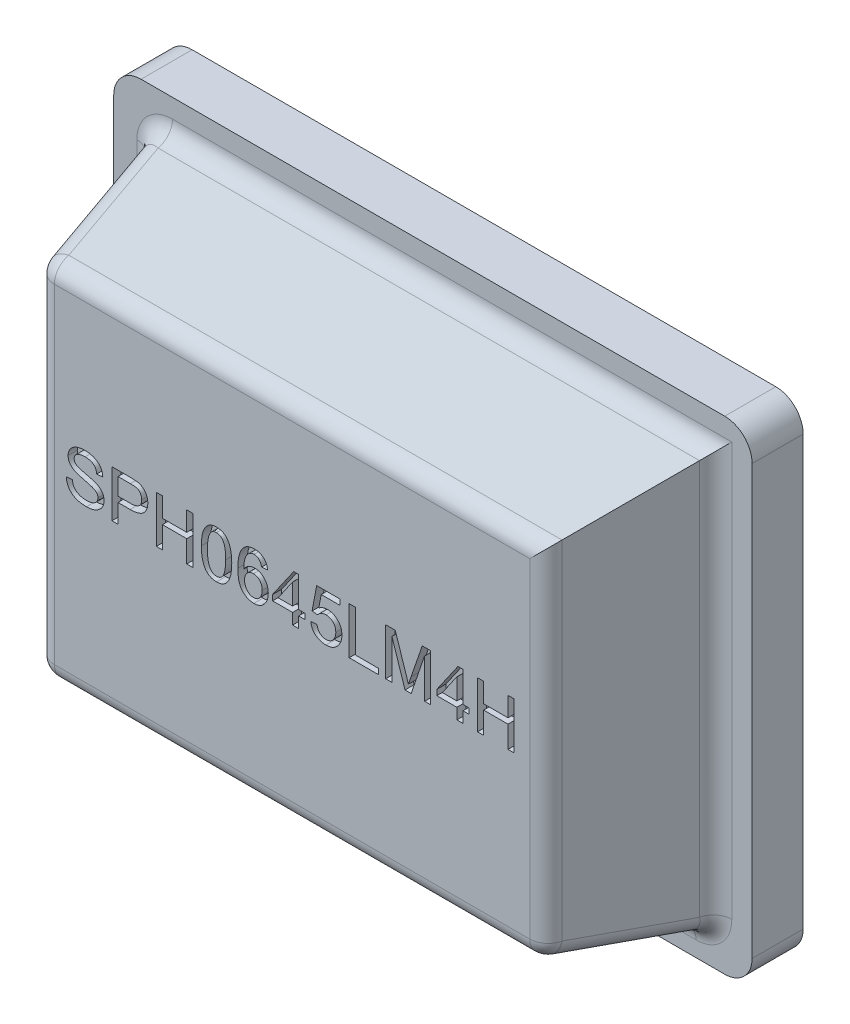
from build123d import *

# Parameters (mm, degrees)
BOSS_EXTRU_1_DEPTH      = 0.28
ESQUISSE2_W             = 3.1
ESQUISSE2_H             = 2.3
BOSS_EXTRU_2_DEPTH      = 0.78
BOSS_EXTRU_2_TAPER      = 12
CONG_1_R                = 0.1
ENL_V_MAT_EXTRU_1_DEPTH = 0.05


with BuildPart() as part:
    # Esquisse1 → Boss.-Extru.1 (new body)
    with BuildSketch(Plane.XY):
        with BuildLine():
            Line((0.15, 0), (3.35, 0))
            ThreePointArc((3.35, 0), (3.456066017, 0.043933983), (3.5, 0.15))
            Line((3.5, 0.15), (3.5, 2.5))
            ThreePointArc((3.5, 2.5), (3.456066017, 2.606066017), (3.35, 2.65))
            Line((3.35, 2.65), (0.15, 2.65))
            ThreePointArc((0.15, 2.65), (0.043933983, 2.606066017), (0, 2.5))
            Line((0, 2.5), (0, 0.15))
            ThreePointArc((0, 0.15), (0.043933983, 0.043933983), (0.15, 0))
        make_face()
    extrude(amount=BOSS_EXTRU_1_DEPTH)

    # Esquisse2 → Boss.-Extru.2 (add)
    with BuildSketch(Plane.XY.offset(0.28)):
        with Locations((1.757802222, 1.315831267)):
            Rectangle(ESQUISSE2_W, ESQUISSE2_H)
    extrude(amount=BOSS_EXTRU_2_DEPTH, taper=BOSS_EXTRU_2_TAPER)

    # Congé1
    cong_1_edges = [part.edges().sort_by_distance(p)[0] for p in [
        (3.307802222, 1.315831267, 0.28),
        (3.224905163, 0.248728326, 0.67),
        (1.757802222, 2.465831267, 0.28),
        (0.207802222, 1.315831267, 0.28),
        (0.290699281, 2.382934208, 0.67),
        (1.757802222, 0.165831267, 0.28),
        (0.290699281, 0.248728326, 0.67),
        (3.142008104, 1.315831267, 1.06),
        (1.757802222, 2.300037149, 1.06),
        (0.37359634, 1.315831267, 1.06),
        (1.757802222, 0.331625385, 1.06),
    ]]
    fillet(cong_1_edges, radius=CONG_1_R)

    # Esquisse3 → Enlèv. mat.-Extru.1 (cut)
    with BuildSketch(Plane.XY.offset(1.06)):
        with BuildLine():
            add(Edge.make_bspline(
                [(0.686708644, 1.433601943), (0.686504725, 1.43562293), (0.686108091, 1.43955386), (0.684873786, 1.445215749), (0.683268561, 1.450504259), (0.681247803, 1.45542207), (0.678770932, 1.459938726), (0.675913819, 1.464100808), (0.672530404, 1.467807634), (0.668775366, 1.471170066), (0.664558544, 1.474094485), (0.659946497, 1.476651772), (0.654913128, 1.478860313), (0.64942557, 1.480616442), (0.643509104, 1.481949886), (0.637191239, 1.482946813), (0.630432628, 1.48350904), (0.62578506, 1.483591547), (0.623386663, 1.483634125)],
                knots=[0, 0, 0, 0, 6.089e-06, 1.1844e-05, 1.735e-05, 2.2654e-05, 2.7762e-05, 3.2779e-05, 3.7761e-05, 4.2781e-05, 4.787e-05, 5.312e-05, 5.8581e-05, 6.4333e-05, 7.0376e-05, 7.6759e-05, 8.3507e-05, 9.0702e-05, 9.0702e-05, 9.0702e-05, 9.0702e-05], degree=3))
            add(Edge.make_bspline(
                [(0.623386663, 1.483634125), (0.62121399, 1.483607457), (0.616967623, 1.483555337), (0.610761815, 1.483051413), (0.604850987, 1.482373919), (0.599274567, 1.481246443), (0.593975058, 1.479906152), (0.588983976, 1.478256413), (0.584312977, 1.476265694), (0.58000664, 1.473983255), (0.576066465, 1.471462847), (0.572662831, 1.468577026), (0.569760216, 1.465433997), (0.567389574, 1.462014967), (0.565532077, 1.458316689), (0.564242188, 1.454327079), (0.563432427, 1.450051385), (0.563342272, 1.447103966), (0.563295928, 1.44558882)],
                knots=[0, 0, 0, 0, 6.516e-06, 1.2736e-05, 1.867e-05, 2.4353e-05, 2.9789e-05, 3.5062e-05, 4.0106e-05, 4.5002e-05, 4.9671e-05, 5.4109e-05, 5.8351e-05, 6.2471e-05, 6.655e-05, 7.0719e-05, 7.5012e-05, 7.9554e-05, 7.9554e-05, 7.9554e-05, 7.9554e-05], degree=3))
            add(Edge.make_bspline(
                [(0.563295928, 1.44558882), (0.563340109, 1.444266954), (0.563426572, 1.441680013), (0.563977787, 1.43792657), (0.565004176, 1.434441006), (0.566323037, 1.431188028), (0.568136658, 1.428245141), (0.570305555, 1.425547274), (0.572851353, 1.423095932), (0.575888084, 1.420910558), (0.57947096, 1.418844765), (0.583744959, 1.416862243), (0.588718663, 1.414795005), (0.59449778, 1.412878645), (0.600954167, 1.410766058), (0.608196515, 1.408754951), (0.616155253, 1.406723822), (0.621733286, 1.405446404), (0.624637468, 1.404781322)],
                knots=[0, 0, 0, 0, 3.966e-06, 7.762e-06, 1.1342e-05, 1.4846e-05, 1.826e-05, 2.167e-05, 2.5209e-05, 2.8826e-05, 3.2866e-05, 3.7599e-05, 4.2951e-05, 4.9016e-05, 5.5856e-05, 6.333e-05, 7.1559e-05, 8.0496e-05, 8.0496e-05, 8.0496e-05, 8.0496e-05], degree=3))
            add(Edge.make_bspline(
                [(0.624637468, 1.404781322), (0.629769119, 1.403628786), (0.639575354, 1.401426368), (0.653475203, 1.397830233), (0.665910853, 1.394243676), (0.67705924, 1.390630254), (0.687146055, 1.386470947), (0.696291146, 1.381234319), (0.704735456, 1.37506955), (0.7111137, 1.369096867), (0.715649875, 1.36376883), (0.718653309, 1.359422065), (0.721136843, 1.354722135), (0.723199876, 1.349696507), (0.724796536, 1.344353518), (0.725946641, 1.338668336), (0.726631977, 1.332668611), (0.726699743, 1.328553557), (0.726734389, 1.326449686)],
                knots=[0, 0, 0, 0, 1.5778e-05, 3.015e-05, 4.3065e-05, 5.4601e-05, 6.5297e-05, 7.5731e-05, 8.6134e-05, 9.6604e-05, 0.000101856, 0.000107103, 0.000112419, 0.000117771, 0.000123377, 0.000129121, 0.000135153, 0.000141462, 0.000141462, 0.000141462, 0.000141462], degree=3))
            add(Edge.make_bspline(
                [(0.726734389, 1.326449686), (0.72665664, 1.323769377), (0.726503298, 1.318483051), (0.725217205, 1.310735349), (0.72313559, 1.303334025), (0.720196405, 1.29629749), (0.71639635, 1.289629279), (0.711790457, 1.283293516), (0.706307393, 1.277331831), (0.700086792, 1.271736517), (0.693205066, 1.266651967), (0.685728734, 1.262258584), (0.677782956, 1.258490024), (0.66932344, 1.255406898), (0.660343525, 1.253091494), (0.650891838, 1.251347698), (0.640900726, 1.250378547), (0.634072587, 1.250227762), (0.630578789, 1.250150609)],
                knots=[0, 0, 0, 0, 8.037e-06, 1.5851e-05, 2.3489e-05, 3.1058e-05, 3.8667e-05, 4.6464e-05, 5.4507e-05, 6.2921e-05, 7.1531e-05, 8.0129e-05, 8.8895e-05, 9.788e-05, 0.000107095, 0.000116684, 0.000126688, 0.000137169, 0.000137169, 0.000137169, 0.000137169], degree=3))
            add(Edge.make_bspline(
                [(0.630578789, 1.250150609), (0.62616366, 1.250212664), (0.617595461, 1.250333091), (0.605175967, 1.251486804), (0.593624562, 1.253395141), (0.582934087, 1.256044889), (0.573075061, 1.25941463), (0.564057257, 1.263572777), (0.555918877, 1.268558097), (0.548640564, 1.274258888), (0.54224423, 1.280583066), (0.536615818, 1.287351617), (0.531776207, 1.294566629), (0.527837127, 1.302290693), (0.524546581, 1.310398153), (0.522186479, 1.31900771), (0.520518245, 1.328041244), (0.520131334, 1.334242641), (0.519934703, 1.337394226)],
                knots=[0, 0, 0, 0, 1.3243e-05, 2.5699e-05, 3.7378e-05, 4.8337e-05, 5.8704e-05, 6.859e-05, 7.8065e-05, 8.7271e-05, 9.6263e-05, 0.000104998, 0.000113641, 0.000122266, 0.000130966, 0.000139843, 0.000149003, 0.000158469, 0.000158469, 0.000158469, 0.000158469], degree=3))
            Line((0.519934703, 1.337394226), (0.553289491, 1.340208536))
            add(Edge.make_bspline(
                [(0.553289491, 1.340208536), (0.553540517, 1.337683447), (0.554030292, 1.332756774), (0.555484797, 1.325662004), (0.557550258, 1.319094159), (0.560309636, 1.313101746), (0.563564585, 1.307579746), (0.56753152, 1.302655137), (0.57204413, 1.298220434), (0.577166402, 1.294400475), (0.582717291, 1.291081432), (0.588561247, 1.288172941), (0.594669199, 1.285626083), (0.601109268, 1.283686002), (0.607793057, 1.282115051), (0.61473775, 1.280967327), (0.621965166, 1.280272554), (0.62687692, 1.280204566), (0.629380102, 1.280169918)],
                knots=[0, 0, 0, 0, 7.609e-06, 1.4845e-05, 2.1685e-05, 2.8216e-05, 3.4597e-05, 4.0864e-05, 4.713e-05, 5.353e-05, 5.9983e-05, 6.6509e-05, 7.31e-05, 7.9809e-05, 8.6661e-05, 9.3687e-05, 0.000100911, 0.000108418, 0.000108418, 0.000108418, 0.000108418], degree=3))
            add(Edge.make_bspline(
                [(0.629380102, 1.280169918), (0.631709619, 1.28018809), (0.636271989, 1.280223679), (0.6429305, 1.280848267), (0.649263821, 1.28167395), (0.655221456, 1.283021405), (0.660863148, 1.284599591), (0.666158462, 1.286598437), (0.671119623, 1.288932486), (0.675697923, 1.291627459), (0.679824903, 1.294642713), (0.683444451, 1.297942315), (0.686562464, 1.301472909), (0.689028443, 1.305342301), (0.69096283, 1.309425309), (0.692401614, 1.313757725), (0.693247452, 1.318373116), (0.693334962, 1.321547195), (0.693379601, 1.323166324)],
                knots=[0, 0, 0, 0, 6.985e-06, 1.3681e-05, 2.0049e-05, 2.6132e-05, 3.1987e-05, 3.7611e-05, 4.309e-05, 4.8417e-05, 5.3525e-05, 5.8394e-05, 6.3086e-05, 6.7611e-05, 7.211e-05, 7.661e-05, 8.1271e-05, 8.6125e-05, 8.6125e-05, 8.6125e-05, 8.6125e-05], degree=3))
            add(Edge.make_bspline(
                [(0.693379601, 1.323166324), (0.693311881, 1.324836734), (0.693179804, 1.328094608), (0.692377587, 1.332812703), (0.690873449, 1.337151472), (0.68885353, 1.34117316), (0.686124915, 1.344769338), (0.682948779, 1.348120846), (0.679061862, 1.350973659), (0.674600802, 1.353542019), (0.669477383, 1.355940824), (0.663606078, 1.35825266), (0.656992374, 1.36065761), (0.649583372, 1.363043331), (0.641386398, 1.365414482), (0.632421332, 1.367899345), (0.622634717, 1.370246892), (0.612327813, 1.372616252), (0.602003992, 1.375056027), (0.592200947, 1.377794332), (0.583165542, 1.380829343), (0.574874106, 1.384035796), (0.567344428, 1.387462259), (0.56058994, 1.391121965), (0.554550928, 1.394947895), (0.549294609, 1.399105248), (0.544700895, 1.403506366), (0.540770542, 1.4082391), (0.537398468, 1.413252345), (0.53468781, 1.418619642), (0.532515319, 1.424286447), (0.53102852, 1.430290688), (0.530123855, 1.436597187), (0.530002851, 1.440895229), (0.529941139, 1.443087211)],
                knots=[0, 0, 0, 0, 5.013e-06, 9.777e-06, 1.4293e-05, 1.8745e-05, 2.3217e-05, 2.7787e-05, 3.255e-05, 3.7619e-05, 4.3214e-05, 4.9504e-05, 5.6544e-05, 6.4323e-05, 7.2849e-05, 8.2142e-05, 9.2229e-05, 0.000103038, 0.000113871, 0.000124051, 0.00013356, 0.000142454, 0.00015071, 0.000158359, 0.000165486, 0.000172128, 0.000178431, 0.000184536, 0.000190549, 0.000196516, 0.000202537, 0.000208718, 0.000215034, 0.000221609, 0.000221609, 0.000221609, 0.000221609], degree=3))
            add(Edge.make_bspline(
                [(0.529941139, 1.443087211), (0.529998287, 1.445594327), (0.530110501, 1.450517213), (0.531380758, 1.457712986), (0.533293477, 1.464567207), (0.535960118, 1.471118022), (0.539506436, 1.477273514), (0.543732448, 1.483157829), (0.548802334, 1.488647737), (0.554569597, 1.493792546), (0.561008211, 1.498461238), (0.568040826, 1.502553606), (0.575639915, 1.505996973), (0.58379326, 1.508798662), (0.59249316, 1.510990884), (0.601748044, 1.512532017), (0.611570797, 1.513486406), (0.618311704, 1.513596788), (0.62177104, 1.513653435)],
                knots=[0, 0, 0, 0, 7.514e-06, 1.4754e-05, 2.1848e-05, 2.8836e-05, 3.5908e-05, 4.3111e-05, 5.0526e-05, 5.8278e-05, 6.6263e-05, 7.4344e-05, 8.2647e-05, 9.125e-05, 0.000100174, 0.00010953, 0.000119373, 0.000129749, 0.000129749, 0.000129749, 0.000129749], degree=3))
            add(Edge.make_bspline(
                [(0.62177104, 1.513653435), (0.625317314, 1.513596958), (0.632249045, 1.513486567), (0.64238107, 1.512521374), (0.651993137, 1.511009323), (0.661037095, 1.508725997), (0.669592812, 1.505955833), (0.677571214, 1.502421231), (0.685085482, 1.498386408), (0.691962639, 1.493619138), (0.698213183, 1.488330473), (0.703762899, 1.482507854), (0.708467779, 1.476105159), (0.712418826, 1.469167412), (0.715531876, 1.461684539), (0.717888412, 1.453684229), (0.719470426, 1.445158667), (0.719862715, 1.439271899), (0.720063432, 1.436259903)],
                knots=[0, 0, 0, 0, 1.0636e-05, 2.0791e-05, 3.0507e-05, 3.9797e-05, 4.8746e-05, 5.7451e-05, 6.5941e-05, 7.4296e-05, 8.2504e-05, 9.0467e-05, 9.8369e-05, 0.000106281, 0.000114363, 0.000122625, 0.000131262, 0.000140313, 0.000140313, 0.000140313, 0.000140313], degree=3))
            Line((0.720063432, 1.436259903), (0.686708644, 1.433601943))
        make_face()
        with BuildLine():
            Line((0.770095614, 1.510317956), (0.867449902, 1.510317956))
            add(Edge.make_bspline(
                [(0.867449902, 1.510317956), (0.871150456, 1.510284259), (0.878293426, 1.510219215), (0.888620564, 1.509827351), (0.898142542, 1.509074761), (0.906988373, 1.508168394), (0.915306326, 1.506575638), (0.923250381, 1.504048637), (0.930871363, 1.500594063), (0.938123549, 1.496263555), (0.944872396, 1.491112656), (0.950744594, 1.484937979), (0.955763662, 1.47792977), (0.959745851, 1.470126237), (0.962904336, 1.461867316), (0.965219828, 1.453333975), (0.966606193, 1.444591853), (0.966794413, 1.438696877), (0.966888864, 1.435738734)],
                knots=[0, 0, 0, 0, 1.1102e-05, 2.143e-05, 3.0995e-05, 3.9754e-05, 4.8095e-05, 5.6352e-05, 6.4703e-05, 7.314e-05, 8.1647e-05, 9.0088e-05, 9.8606e-05, 0.000107418, 0.000116293, 0.000125092, 0.000133901, 0.000142773, 0.000142773, 0.000142773, 0.000142773], degree=3))
            add(Edge.make_bspline(
                [(0.966888864, 1.435738734), (0.966823393, 1.432833618), (0.966695102, 1.42714098), (0.96555628, 1.418841889), (0.963827127, 1.410948882), (0.961244185, 1.403538071), (0.958002109, 1.396540015), (0.954029681, 1.38999108), (0.949283942, 1.383912914), (0.943865344, 1.378251122), (0.937617785, 1.373137875), (0.93046525, 1.368769347), (0.922473972, 1.365054203), (0.913610193, 1.362050983), (0.903873795, 1.359718382), (0.893273018, 1.35810778), (0.881822087, 1.357017268), (0.873897776, 1.356930732), (0.86979516, 1.35688593)],
                knots=[0, 0, 0, 0, 8.711e-06, 1.707e-05, 2.5086e-05, 3.2914e-05, 4.0562e-05, 4.8186e-05, 5.5838e-05, 6.3652e-05, 7.1653e-05, 7.9984e-05, 8.8728e-05, 9.804e-05, 0.000108013, 0.000118723, 0.000130184, 0.000142488, 0.000142488, 0.000142488, 0.000142488], degree=3))
            Line((0.86979516, 1.35688593), (0.803450402, 1.35688593))
            Line((0.803450402, 1.35688593), (0.803450402, 1.253486087))
            Line((0.803450402, 1.253486087), (0.770095614, 1.253486087))
            Line((0.770095614, 1.253486087), (0.770095614, 1.510317956))
        make_face()
        with BuildLine():
            Line((0.803450402, 1.38690524), (0.871306549, 1.38690524))
            add(Edge.make_bspline(
                [(0.871306549, 1.38690524), (0.873826179, 1.386952707), (0.878697205, 1.387044472), (0.885768511, 1.387536868), (0.89232978, 1.388479628), (0.898439312, 1.389759448), (0.904036919, 1.391493732), (0.909208768, 1.393477719), (0.91380494, 1.395994869), (0.918032613, 1.39868986), (0.921645174, 1.401956234), (0.924860491, 1.405482196), (0.927548296, 1.409454916), (0.929715996, 1.413793402), (0.931479433, 1.418482506), (0.932636378, 1.423567554), (0.933386139, 1.429010793), (0.933483833, 1.432765428), (0.933534076, 1.434696397)],
                knots=[0, 0, 0, 0, 7.56e-06, 1.4615e-05, 2.1248e-05, 2.7433e-05, 3.3318e-05, 3.8815e-05, 4.4015e-05, 4.9016e-05, 5.3816e-05, 5.8577e-05, 6.3304e-05, 6.8152e-05, 7.3099e-05, 7.8294e-05, 8.3763e-05, 8.9554e-05, 8.9554e-05, 8.9554e-05, 8.9554e-05], degree=3))
            add(Edge.make_bspline(
                [(0.933534076, 1.434696397), (0.933434094, 1.437240282), (0.93323844, 1.442218428), (0.931696519, 1.449451146), (0.929105265, 1.456208597), (0.925583105, 1.462388937), (0.921408462, 1.467845614), (0.916582207, 1.47218953), (0.911339259, 1.475507243), (0.905351272, 1.477545907), (0.89849859, 1.478771908), (0.890456379, 1.479703858), (0.880988139, 1.480166636), (0.874208072, 1.480252605), (0.870576913, 1.480298647)],
                knots=[0, 0, 0, 0, 7.627e-06, 1.4925e-05, 2.2068e-05, 2.9257e-05, 3.62e-05, 4.2584e-05, 4.8644e-05, 5.4678e-05, 6.1423e-05, 6.9504e-05, 7.8952e-05, 8.9846e-05, 8.9846e-05, 8.9846e-05, 8.9846e-05], degree=3))
            Line((0.870576913, 1.480298647), (0.803450402, 1.480298647))
            Line((0.803450402, 1.480298647), (0.803450402, 1.38690524))
        make_face(mode=Mode.SUBTRACT)
        Polygon((1.213714296, 1.253486087), (1.180359508, 1.253486087), (1.180359508, 1.373563325), (1.046940355, 1.373563325), (1.046940355, 1.253486087), (1.013585567, 1.253486087), (1.013585567, 1.510317956), (1.046940355, 1.510317956), (1.046940355, 1.403582634), (1.180359508, 1.403582634), (1.180359508, 1.510317956), (1.213714296, 1.510317956), align=None)
        with BuildLine():
            add(Edge.make_bspline(
                [(1.343693736, 1.510317956), (1.34706964, 1.510219257), (1.353631171, 1.510027423), (1.363156234, 1.508499669), (1.372026803, 1.505935821), (1.380290402, 1.502397987), (1.387853103, 1.497758961), (1.394761633, 1.492115008), (1.400991269, 1.485420007), (1.40659084, 1.47772986), (1.411407889, 1.468968309), (1.415711681, 1.459290763), (1.419281877, 1.448550327), (1.422157012, 1.436795089), (1.424452516, 1.424055451), (1.426017024, 1.41030252), (1.427036932, 1.395537376), (1.427134527, 1.385343567), (1.42718494, 1.380077932)],
                knots=[0, 0, 0, 0, 1.0124e-05, 1.9678e-05, 2.8848e-05, 3.7765e-05, 4.656e-05, 5.5375e-05, 6.4446e-05, 7.3922e-05, 8.3838e-05, 9.4385e-05, 0.000105658, 0.000117742, 0.000130663, 0.000144465, 0.000159247, 0.000175042, 0.000175042, 0.000175042, 0.000175042], degree=3))
            add(Edge.make_bspline(
                [(1.42718494, 1.380077932), (1.427139688, 1.374759948), (1.427052194, 1.364477714), (1.425965372, 1.349591065), (1.424344311, 1.335753319), (1.422038431, 1.322941889), (1.418964642, 1.311205587), (1.415290483, 1.300498293), (1.410919217, 1.290847628), (1.405860094, 1.282242202), (1.400144784, 1.274680719), (1.393857473, 1.268087861), (1.386945959, 1.262513154), (1.379399012, 1.258010407), (1.371329068, 1.254418975), (1.362632502, 1.251918068), (1.353349999, 1.250459479), (1.346964993, 1.250255245), (1.343693736, 1.250150609)],
                knots=[0, 0, 0, 0, 1.5951e-05, 3.0841e-05, 4.4752e-05, 5.7734e-05, 6.9857e-05, 8.1114e-05, 9.1656e-05, 0.000101586, 0.000110998, 0.000120029, 0.000128852, 0.000137549, 0.000146322, 0.000155278, 0.000164618, 0.000174429, 0.000174429, 0.000174429, 0.000174429], degree=3))
            add(Edge.make_bspline(
                [(1.343693736, 1.250150609), (1.340317824, 1.250249536), (1.333756279, 1.250441816), (1.324247842, 1.251963771), (1.315407627, 1.254526814), (1.307209151, 1.258097082), (1.299603626, 1.262642377), (1.292769907, 1.268346209), (1.286542692, 1.27498864), (1.281009962, 1.282675627), (1.276110347, 1.291365477), (1.271914547, 1.301076896), (1.268306029, 1.311757487), (1.26543469, 1.323481897), (1.263143587, 1.336204548), (1.261581668, 1.349940431), (1.260558475, 1.364670493), (1.260461234, 1.374829643), (1.260410999, 1.380077932)],
                knots=[0, 0, 0, 0, 1.0124e-05, 1.9678e-05, 2.8798e-05, 3.7667e-05, 4.6435e-05, 5.5284e-05, 6.428e-05, 7.3683e-05, 8.3626e-05, 9.4151e-05, 0.000105374, 0.000117408, 0.000130329, 0.000144131, 0.000158861, 0.000174604, 0.000174604, 0.000174604, 0.000174604], degree=3))
            add(Edge.make_bspline(
                [(1.260410999, 1.380077932), (1.260455294, 1.385396085), (1.260540936, 1.395678647), (1.261641926, 1.41058022), (1.263222045, 1.424446014), (1.265642609, 1.437251263), (1.268623489, 1.449024867), (1.272296795, 1.459748275), (1.2766892, 1.469422828), (1.281737104, 1.478066335), (1.287433529, 1.485680056), (1.293753208, 1.492278299), (1.300642433, 1.497878335), (1.308125718, 1.502492478), (1.316216724, 1.505971947), (1.32486043, 1.508489539), (1.334084521, 1.510025254), (1.34043914, 1.510218819), (1.343693736, 1.510317956)],
                knots=[0, 0, 0, 0, 1.5951e-05, 3.0841e-05, 4.4804e-05, 5.7795e-05, 6.9905e-05, 8.1212e-05, 9.1753e-05, 0.000101728, 0.000111182, 0.000120213, 0.000129069, 0.000137748, 0.000146501, 0.000155406, 0.000164703, 0.000174462, 0.000174462, 0.000174462, 0.000174462], degree=3))
        make_face()
        with BuildLine():
            add(Edge.make_bspline(
                [(1.343797969, 1.276834439), (1.345801811, 1.27689629), (1.349722622, 1.277017309), (1.355390061, 1.278205274), (1.36070139, 1.280092595), (1.365616606, 1.282773574), (1.370169057, 1.286196283), (1.374233405, 1.290457486), (1.378026712, 1.29537131), (1.381349605, 1.301137753), (1.384358778, 1.307719017), (1.386852764, 1.315265663), (1.389045827, 1.323723672), (1.390777079, 1.333150968), (1.392180124, 1.343515043), (1.393147401, 1.354855234), (1.393706792, 1.367147231), (1.39378805, 1.375664764), (1.393830152, 1.380077932)],
                knots=[0, 0, 0, 0, 6.005e-06, 1.1749e-05, 1.7288e-05, 2.2861e-05, 2.848e-05, 3.4303e-05, 4.0474e-05, 4.7061e-05, 5.4221e-05, 6.2149e-05, 7.0871e-05, 8.0418e-05, 9.0884e-05, 0.000102237, 0.00011455, 0.000127789, 0.000127789, 0.000127789, 0.000127789], degree=3))
            add(Edge.make_bspline(
                [(1.393830152, 1.380077932), (1.393807716, 1.383170417), (1.39376397, 1.389200124), (1.393495389, 1.39799191), (1.393105781, 1.406283495), (1.392469892, 1.414050191), (1.391694845, 1.421297754), (1.390775855, 1.428048128), (1.389630428, 1.434288097), (1.388319977, 1.44005889), (1.386878159, 1.445409744), (1.385187482, 1.450372742), (1.383393458, 1.454995761), (1.38140311, 1.45926918), (1.379198116, 1.463169833), (1.376896573, 1.466789873), (1.374299081, 1.469978461), (1.371586771, 1.472858301), (1.368721493, 1.475444585), (1.365634789, 1.477631154), (1.362366246, 1.479477546), (1.358920737, 1.480977069), (1.355317934, 1.48219856), (1.351522379, 1.483012389), (1.347549337, 1.483564834), (1.344824923, 1.483610696), (1.343433151, 1.483634125)],
                knots=[0, 0, 0, 0, 9.277e-06, 1.8089e-05, 2.6386e-05, 3.4177e-05, 4.1463e-05, 4.8251e-05, 5.4609e-05, 6.0488e-05, 6.6001e-05, 7.1225e-05, 7.621e-05, 8.0873e-05, 8.5352e-05, 8.9646e-05, 9.3724e-05, 9.7668e-05, 0.000101507, 0.000105282, 0.000108992, 0.000112749, 0.00011654, 0.000120384, 0.000124379, 0.000128551, 0.000128551, 0.000128551, 0.000128551], degree=3))
            add(Edge.make_bspline(
                [(1.343433151, 1.483634125), (1.341429613, 1.483571233), (1.337509395, 1.483448175), (1.331831844, 1.482273604), (1.326537191, 1.480332126), (1.321654757, 1.477573843), (1.317115355, 1.474112044), (1.313031298, 1.469809855), (1.30931382, 1.464772829), (1.306033561, 1.458910665), (1.30310679, 1.452226062), (1.300578409, 1.444654285), (1.298446198, 1.436151515), (1.296775154, 1.426724357), (1.295429474, 1.416376363), (1.294446207, 1.405110031), (1.293889866, 1.392904329), (1.293808143, 1.384456319), (1.293765787, 1.380077932)],
                knots=[0, 0, 0, 0, 6.005e-06, 1.1749e-05, 1.7306e-05, 2.2859e-05, 2.8509e-05, 3.4369e-05, 4.0592e-05, 4.7244e-05, 5.4478e-05, 6.2454e-05, 7.1163e-05, 8.0752e-05, 9.116e-05, 0.000102461, 0.000114669, 0.000127804, 0.000127804, 0.000127804, 0.000127804], degree=3))
            add(Edge.make_bspline(
                [(1.293765787, 1.380077932), (1.293788189, 1.377020183), (1.293831855, 1.371059936), (1.294100684, 1.362372433), (1.294489923, 1.354167462), (1.295134662, 1.346454166), (1.295881407, 1.339217708), (1.296887215, 1.332476918), (1.298019917, 1.326233844), (1.299308584, 1.320451178), (1.300850239, 1.315107211), (1.302483862, 1.31012035), (1.304331591, 1.305500023), (1.306300432, 1.301203584), (1.308465737, 1.297257849), (1.310844761, 1.293687362), (1.313327675, 1.290426265), (1.316047991, 1.287558326), (1.318936744, 1.285040169), (1.321980738, 1.282829606), (1.325180435, 1.280946222), (1.328596377, 1.279494843), (1.33213495, 1.278258001), (1.335884736, 1.277469335), (1.339785054, 1.276901317), (1.342440711, 1.276857059), (1.343797969, 1.276834439)],
                knots=[0, 0, 0, 0, 9.173e-06, 1.7881e-05, 2.6074e-05, 3.3812e-05, 4.1098e-05, 4.7894e-05, 5.4252e-05, 6.0131e-05, 6.5658e-05, 7.0932e-05, 7.5868e-05, 8.0578e-05, 8.5103e-05, 8.9353e-05, 9.3439e-05, 9.7384e-05, 0.000101189, 0.000104921, 0.000108657, 0.000112298, 0.000116039, 0.000119883, 0.000123775, 0.000127843, 0.000127843, 0.000127843, 0.000127843], degree=3))
        make_face(mode=Mode.SUBTRACT)
        with BuildLine():
            add(Edge.make_bspline(
                [(1.493894516, 1.386436188), (1.495673452, 1.389122908), (1.499145677, 1.394366996), (1.505293715, 1.401293259), (1.512036536, 1.407141077), (1.519304957, 1.411979513), (1.527161933, 1.415738038), (1.535599626, 1.418305359), (1.544554201, 1.419996505), (1.550728669, 1.420170961), (1.553881018, 1.420260028)],
                knots=[0, 0, 0, 0, 9.658e-06, 1.8851e-05, 2.7681e-05, 3.6368e-05, 4.497e-05, 5.3706e-05, 6.2763e-05, 7.2211e-05, 7.2211e-05, 7.2211e-05, 7.2211e-05], degree=3))
            add(Edge.make_bspline(
                [(1.553881018, 1.420260028), (1.556386533, 1.420191345), (1.561335126, 1.420055692), (1.56860602, 1.418936028), (1.575566637, 1.417097861), (1.582266919, 1.414601553), (1.588624666, 1.411262817), (1.594781916, 1.407311838), (1.600549645, 1.402518187), (1.606010093, 1.397127742), (1.610980865, 1.391157943), (1.615402889, 1.384750101), (1.619030337, 1.377864669), (1.622091126, 1.370641758), (1.624438352, 1.36299073), (1.626072373, 1.354925211), (1.627171351, 1.346475381), (1.627265673, 1.34069854), (1.627313668, 1.337759044)],
                knots=[0, 0, 0, 0, 7.514e-06, 1.484e-05, 2.2008e-05, 2.9083e-05, 3.6239e-05, 4.3511e-05, 5.0991e-05, 5.8693e-05, 6.6501e-05, 7.4263e-05, 8.2004e-05, 8.9806e-05, 9.7768e-05, 0.000105965, 0.000114472, 0.000123286, 0.000123286, 0.000123286, 0.000123286], degree=3))
            add(Edge.make_bspline(
                [(1.627313668, 1.337759044), (1.627266587, 1.334767258), (1.627174036, 1.328886196), (1.626056974, 1.320250089), (1.624451968, 1.311929891), (1.62200695, 1.303996067), (1.619002474, 1.296362967), (1.615199427, 1.289124247), (1.610839102, 1.282136184), (1.605738248, 1.275641884), (1.600181426, 1.269621807), (1.594008991, 1.264461725), (1.587512465, 1.259963446), (1.580471436, 1.256425849), (1.573048423, 1.25356379), (1.565130653, 1.251624543), (1.556786567, 1.25038425), (1.551071286, 1.25022967), (1.548148164, 1.250150609)],
                knots=[0, 0, 0, 0, 8.97e-06, 1.7632e-05, 2.6085e-05, 3.4361e-05, 4.25e-05, 5.0659e-05, 5.8857e-05, 6.7176e-05, 7.5398e-05, 8.3386e-05, 9.1264e-05, 9.9049e-05, 0.000106966, 0.000115081, 0.000123454, 0.00013222, 0.00013222, 0.00013222, 0.00013222], degree=3))
            add(Edge.make_bspline(
                [(1.548148164, 1.250150609), (1.545171857, 1.25022168), (1.539294071, 1.250362037), (1.530663827, 1.2517503), (1.522338798, 1.253766791), (1.514399092, 1.256820271), (1.506749201, 1.260598661), (1.49949995, 1.265360628), (1.492518418, 1.270844327), (1.487073146, 1.276103907), (1.482964221, 1.280802598), (1.480080988, 1.284704229), (1.477316448, 1.288906084), (1.474867566, 1.293482983), (1.472536093, 1.298356755), (1.470490718, 1.303582374), (1.468528291, 1.309090884), (1.466893955, 1.314973276), (1.465371025, 1.321155269), (1.464080042, 1.327678065), (1.462977403, 1.33452655), (1.46212509, 1.341710731), (1.461356015, 1.349212511), (1.460935785, 1.357056271), (1.460591456, 1.365221598), (1.460557181, 1.370783339), (1.460539728, 1.373615441)],
                knots=[0, 0, 0, 0, 8.922e-06, 1.7619e-05, 2.6164e-05, 3.4576e-05, 4.3083e-05, 5.1713e-05, 6.0544e-05, 6.9685e-05, 7.4377e-05, 7.9255e-05, 8.4228e-05, 8.9452e-05, 9.4814e-05, 0.000100427, 0.000106278, 0.000112349, 0.000118732, 0.000125376, 0.00013229, 0.000139537, 0.000147077, 0.000154909, 0.000163097, 0.000171593, 0.000171593, 0.000171593, 0.000171593], degree=3))
            add(Edge.make_bspline(
                [(1.460539728, 1.373615441), (1.460604806, 1.379124397), (1.46073079, 1.389789033), (1.461837451, 1.405255635), (1.463630054, 1.419667934), (1.466153969, 1.433030272), (1.4694235, 1.4453379), (1.473420708, 1.456596691), (1.478157705, 1.466821743), (1.483625567, 1.475990892), (1.489812113, 1.484092956), (1.496658245, 1.491130871), (1.504192582, 1.497083878), (1.512355909, 1.501984282), (1.521241936, 1.505679879), (1.530712365, 1.508401343), (1.540863854, 1.510051093), (1.547846573, 1.510227426), (1.551431525, 1.510317956)],
                knots=[0, 0, 0, 0, 1.6525e-05, 3.199e-05, 4.649e-05, 6.0074e-05, 7.2754e-05, 8.4656e-05, 9.5871e-05, 0.000106507, 0.000116618, 0.000126385, 0.000135883, 0.000145349, 0.000154854, 0.000164669, 0.000174856, 0.000185605, 0.000185605, 0.000185605, 0.000185605], degree=3))
            add(Edge.make_bspline(
                [(1.551431525, 1.510317956), (1.553778612, 1.510265367), (1.558380093, 1.510162266), (1.565144795, 1.509426354), (1.571631559, 1.508179667), (1.577860453, 1.506406916), (1.583801536, 1.504106911), (1.589480366, 1.501335028), (1.594843044, 1.498039071), (1.599930013, 1.494288227), (1.604616788, 1.49001611), (1.608878627, 1.48524269), (1.612624755, 1.479949066), (1.615928618, 1.474200189), (1.618694639, 1.467938564), (1.62096525, 1.461200681), (1.622824826, 1.453993662), (1.623587853, 1.448984962), (1.62397819, 1.44642269)],
                knots=[0, 0, 0, 0, 7.041e-06, 1.3803e-05, 2.0386e-05, 2.6836e-05, 3.3204e-05, 3.9474e-05, 4.5767e-05, 5.2062e-05, 5.8408e-05, 6.4757e-05, 7.1221e-05, 7.7828e-05, 8.4617e-05, 9.1721e-05, 9.914e-05, 0.000106912, 0.000106912, 0.000106912, 0.000106912], degree=3))
            Line((1.62397819, 1.44642269), (1.590623402, 1.44360838))
            add(Edge.make_bspline(
                [(1.590623402, 1.44360838), (1.589880901, 1.446756337), (1.588469869, 1.452738653), (1.585300663, 1.460981808), (1.58127881, 1.467971852), (1.576433966, 1.473734311), (1.570755452, 1.478205768), (1.564284676, 1.481400159), (1.557011693, 1.48331142), (1.551895063, 1.48352395), (1.549242618, 1.483634125)],
                knots=[0, 0, 0, 0, 9.696e-06, 1.8425e-05, 2.639e-05, 3.3784e-05, 4.0873e-05, 4.7912e-05, 5.5294e-05, 6.3241e-05, 6.3241e-05, 6.3241e-05, 6.3241e-05], degree=3))
            add(Edge.make_bspline(
                [(1.549242618, 1.483634125), (1.54736125, 1.483564302), (1.543618457, 1.483425395), (1.538125331, 1.482300771), (1.532838173, 1.480445654), (1.527758982, 1.477868811), (1.522861451, 1.474555515), (1.518243229, 1.470426627), (1.513735473, 1.465684879), (1.509501994, 1.46018363), (1.505616938, 1.453884917), (1.502231134, 1.446724528), (1.499476174, 1.43869964), (1.497081721, 1.429884915), (1.495394571, 1.420195676), (1.494080446, 1.409692725), (1.493302075, 1.398347862), (1.493211715, 1.390502506), (1.493894516, 1.386436188)],
                knots=[0, 0, 0, 0, 5.64e-06, 1.1221e-05, 1.6743e-05, 2.2406e-05, 2.8261e-05, 3.4428e-05, 4.0954e-05, 4.7865e-05, 5.5213e-05, 6.3116e-05, 7.1572e-05, 8.0636e-05, 9.049e-05, 0.000101046, 0.000112383, 0.000124581, 0.000124581, 0.000124581, 0.000124581], degree=3))
        make_face()
        with BuildLine():
            add(Edge.make_bspline(
                [(1.54721006, 1.276834439), (1.548915203, 1.276883803), (1.552257274, 1.276980556), (1.557148596, 1.2777618), (1.561749473, 1.279147171), (1.56614543, 1.280968224), (1.570266512, 1.283388912), (1.574147446, 1.286329485), (1.57776131, 1.28979713), (1.581061735, 1.293753485), (1.584070425, 1.298065268), (1.586731107, 1.302645347), (1.588979987, 1.30745949), (1.590806644, 1.312482591), (1.592228635, 1.317729418), (1.593185331, 1.323209026), (1.593848077, 1.328900493), (1.59392157, 1.332771242), (1.59395888, 1.334736267)],
                knots=[0, 0, 0, 0, 5.114e-06, 1.0024e-05, 1.4806e-05, 1.95e-05, 2.4265e-05, 2.9101e-05, 3.4078e-05, 3.9256e-05, 4.4533e-05, 4.9834e-05, 5.5126e-05, 6.0452e-05, 6.585e-05, 7.1411e-05, 7.7126e-05, 8.3019e-05, 8.3019e-05, 8.3019e-05, 8.3019e-05], degree=3))
            add(Edge.make_bspline(
                [(1.59395888, 1.334736267), (1.593921545, 1.336701228), (1.593848328, 1.340554582), (1.593196322, 1.346178927), (1.592219854, 1.351551258), (1.590815638, 1.356664411), (1.588987551, 1.361533192), (1.586741891, 1.366144222), (1.584063788, 1.370471967), (1.581059579, 1.374543078), (1.577703419, 1.378228896), (1.574020599, 1.381431554), (1.570080932, 1.384176826), (1.565849547, 1.386422338), (1.56131938, 1.388166774), (1.556499534, 1.389335686), (1.551420344, 1.390089202), (1.547942448, 1.390189525), (1.546167723, 1.390240719)],
                knots=[0, 0, 0, 0, 5.893e-06, 1.1556e-05, 1.6964e-05, 2.2261e-05, 2.744e-05, 3.2545e-05, 3.7622e-05, 4.2687e-05, 4.7704e-05, 5.2543e-05, 5.73e-05, 6.2079e-05, 6.688e-05, 7.1822e-05, 7.693e-05, 8.2252e-05, 8.2252e-05, 8.2252e-05, 8.2252e-05], degree=3))
            add(Edge.make_bspline(
                [(1.546167723, 1.390240719), (1.54453136, 1.390211646), (1.541293671, 1.390154124), (1.536537175, 1.389362606), (1.531931223, 1.388254712), (1.527508277, 1.386591741), (1.523236061, 1.38454672), (1.519205137, 1.381913222), (1.515254905, 1.378972399), (1.511605725, 1.37547604), (1.508222943, 1.371664572), (1.505282481, 1.367498637), (1.50276224, 1.363057058), (1.500721202, 1.358283807), (1.499180195, 1.353208243), (1.498017991, 1.347861176), (1.497334279, 1.342224232), (1.497265201, 1.338368938), (1.497229995, 1.336404006)],
                knots=[0, 0, 0, 0, 4.903e-06, 9.702e-06, 1.4429e-05, 1.9096e-05, 2.3851e-05, 2.8607e-05, 3.3517e-05, 3.8605e-05, 4.3738e-05, 4.8784e-05, 5.3872e-05, 5.9032e-05, 6.4323e-05, 6.9761e-05, 7.5431e-05, 8.1324e-05, 8.1324e-05, 8.1324e-05, 8.1324e-05], degree=3))
            add(Edge.make_bspline(
                [(1.497229995, 1.336404006), (1.497263606, 1.334386614), (1.497329867, 1.330409483), (1.498047451, 1.324558151), (1.499109353, 1.318918402), (1.500686951, 1.313510335), (1.502735902, 1.308341705), (1.505178424, 1.303381933), (1.508068585, 1.298650555), (1.511369702, 1.29422412), (1.514992431, 1.290150083), (1.518921679, 1.286610095), (1.52302891, 1.283519086), (1.527476177, 1.281153552), (1.532059753, 1.27917382), (1.53691858, 1.277838696), (1.541983899, 1.276963848), (1.545451702, 1.276877979), (1.54721006, 1.276834439)],
                knots=[0, 0, 0, 0, 6.049e-06, 1.1925e-05, 1.7659e-05, 2.3251e-05, 2.8796e-05, 3.432e-05, 3.9817e-05, 4.5404e-05, 5.0866e-05, 5.6142e-05, 6.125e-05, 6.6241e-05, 7.1216e-05, 7.6199e-05, 8.1323e-05, 8.6593e-05, 8.6593e-05, 8.6593e-05, 8.6593e-05], degree=3))
        make_face(mode=Mode.SUBTRACT)
        Polygon((1.827442397, 1.313524706), (1.794087609, 1.313524706), (1.794087609, 1.253486087), (1.760732821, 1.253486087), (1.760732821, 1.313524706), (1.65066202, 1.313524706), (1.65066202, 1.343544015), (1.766674143, 1.510317956), (1.794087609, 1.510317956), (1.794087609, 1.343544015), (1.827442397, 1.343544015), align=None)
        Polygon((1.760732821, 1.343544015), (1.760732821, 1.457471463), (1.681515199, 1.343544015), align=None, mode=Mode.SUBTRACT)
        with BuildLine():
            add(Edge.make_bspline(
                [(1.904418994, 1.406813879), (1.906350979, 1.408137193), (1.91014626, 1.41073677), (1.915990338, 1.414230046), (1.921955024, 1.417051259), (1.927909049, 1.419520702), (1.933961022, 1.421314542), (1.940055641, 1.422639362), (1.9461952, 1.423441845), (1.950314288, 1.423544408), (1.952366502, 1.423595507)],
                knots=[0, 0, 0, 0, 7.025e-06, 1.38e-05, 2.0397e-05, 2.6804e-05, 3.3118e-05, 3.9303e-05, 4.5502e-05, 5.1657e-05, 5.1657e-05, 5.1657e-05, 5.1657e-05], degree=3))
            add(Edge.make_bspline(
                [(1.952366502, 1.423595507), (1.954958378, 1.42352281), (1.960076413, 1.423379261), (1.967638472, 1.422313529), (1.974933108, 1.420544412), (1.981990725, 1.418074546), (1.988763056, 1.414891188), (1.995285836, 1.41099023), (2.001538189, 1.406386907), (2.007491332, 1.401148467), (2.013040435, 1.39538488), (2.01775532, 1.388956295), (2.021908174, 1.382163959), (2.025137618, 1.374810075), (2.027810561, 1.367052016), (2.029578049, 1.358791655), (2.030714968, 1.350073087), (2.030841642, 1.344103708), (2.030906605, 1.341042406)],
                knots=[0, 0, 0, 0, 7.774e-06, 1.5351e-05, 2.2859e-05, 3.026e-05, 3.7744e-05, 4.527e-05, 5.3025e-05, 6.1002e-05, 6.9039e-05, 7.6971e-05, 8.4872e-05, 9.2873e-05, 0.000101015, 0.000109449, 0.000118169, 0.000127349, 0.000127349, 0.000127349, 0.000127349], degree=3))
            add(Edge.make_bspline(
                [(2.030906605, 1.341042406), (2.030843767, 1.337946162), (2.030719762, 1.331835998), (2.029519747, 1.322859253), (2.027690802, 1.314224555), (2.0249669, 1.305975599), (2.021622388, 1.298037333), (2.017401836, 1.290502302), (2.012466814, 1.283314373), (2.006842495, 1.276534542), (2.000577625, 1.27036594), (1.993794579, 1.26493527), (1.986552217, 1.260331124), (1.978791053, 1.256612798), (1.970592988, 1.253659614), (1.961890873, 1.251683173), (1.952753955, 1.25036805), (1.9464995, 1.250224225), (1.943298169, 1.250150609)],
                knots=[0, 0, 0, 0, 9.284e-06, 1.8321e-05, 2.7123e-05, 3.5726e-05, 4.4342e-05, 5.2927e-05, 6.1586e-05, 7.0468e-05, 7.9312e-05, 8.7916e-05, 9.649e-05, 0.000104998, 0.000113685, 0.000122572, 0.000131726, 0.000141325, 0.000141325, 0.000141325, 0.000141325], degree=3))
            add(Edge.make_bspline(
                [(1.943298169, 1.250150609), (1.940672644, 1.250195251), (1.935494731, 1.250283292), (1.927861938, 1.251143719), (1.920485763, 1.252536347), (1.913384379, 1.254540021), (1.906531783, 1.257017753), (1.899971367, 1.260135695), (1.893677111, 1.263775956), (1.887670692, 1.267941418), (1.882072659, 1.272629489), (1.877170073, 1.278021837), (1.872797376, 1.283854587), (1.869158568, 1.290290606), (1.866052647, 1.297206506), (1.863612579, 1.304682328), (1.861839708, 1.31271806), (1.861151012, 1.318277521), (1.860797185, 1.321133767)],
                knots=[0, 0, 0, 0, 7.874e-06, 1.5529e-05, 2.3011e-05, 3.037e-05, 3.7641e-05, 4.4845e-05, 5.213e-05, 5.9431e-05, 6.6752e-05, 7.3981e-05, 8.1246e-05, 8.8577e-05, 9.6112e-05, 0.000103957, 0.000112125, 0.000120756, 0.000120756, 0.000120756, 0.000120756], degree=3))
            Line((1.860797185, 1.321133767), (1.894151973, 1.323531142))
            add(Edge.make_bspline(
                [(1.894151973, 1.323531142), (1.894511385, 1.32163266), (1.895211833, 1.317932754), (1.896617334, 1.312597649), (1.898328591, 1.307625644), (1.900372405, 1.303034201), (1.902646499, 1.298799115), (1.905236021, 1.294946991), (1.90808046, 1.29145616), (1.911237854, 1.288359515), (1.914632701, 1.285645603), (1.918235858, 1.283304377), (1.922012864, 1.281293496), (1.926006376, 1.279695778), (1.930158448, 1.278360485), (1.934534538, 1.277516202), (1.939075936, 1.276889119), (1.942184003, 1.276852893), (1.943767221, 1.276834439)],
                knots=[0, 0, 0, 0, 5.795e-06, 1.1294e-05, 1.6536e-05, 2.1552e-05, 2.6356e-05, 3.0938e-05, 3.5456e-05, 3.9842e-05, 4.418e-05, 4.8473e-05, 5.2716e-05, 5.6994e-05, 6.1362e-05, 6.5777e-05, 7.0348e-05, 7.5093e-05, 7.5093e-05, 7.5093e-05, 7.5093e-05], degree=3))
            add(Edge.make_bspline(
                [(1.943767221, 1.276834439), (1.94571639, 1.276877201), (1.949546544, 1.27696123), (1.955147306, 1.277840329), (1.960492016, 1.279159793), (1.965517941, 1.28111596), (1.970268756, 1.283578113), (1.974701736, 1.28663772), (1.978912077, 1.290182623), (1.982711115, 1.294309048), (1.986218358, 1.298765079), (1.989225802, 1.303567311), (1.991793277, 1.308612614), (1.993946917, 1.313864289), (1.995573456, 1.319403126), (1.996678558, 1.325182677), (1.997468224, 1.331205509), (1.997523622, 1.335306879), (1.997551817, 1.337394226)],
                knots=[0, 0, 0, 0, 5.843e-06, 1.1481e-05, 1.6967e-05, 2.2329e-05, 2.7621e-05, 3.2984e-05, 3.8456e-05, 4.4097e-05, 4.9779e-05, 5.5447e-05, 6.1064e-05, 6.6745e-05, 7.2451e-05, 7.8349e-05, 8.4386e-05, 9.0644e-05, 9.0644e-05, 9.0644e-05, 9.0644e-05], degree=3))
            add(Edge.make_bspline(
                [(1.997551817, 1.337394226), (1.997493906, 1.339514965), (1.997381107, 1.343645805), (1.996733417, 1.349672516), (1.995497471, 1.355327149), (1.993913052, 1.360689249), (1.991778665, 1.36569026), (1.98913669, 1.370327239), (1.98604547, 1.374626358), (1.982510048, 1.378567318), (1.978625599, 1.382110731), (1.974404014, 1.385143619), (1.969967386, 1.387766443), (1.965246784, 1.38994128), (1.960207282, 1.391513815), (1.95493617, 1.39274963), (1.949377321, 1.393403311), (1.945592765, 1.393517812), (1.943662987, 1.393576197)],
                knots=[0, 0, 0, 0, 6.364e-06, 1.2395e-05, 1.815e-05, 2.3706e-05, 2.9146e-05, 3.4421e-05, 3.9686e-05, 4.5001e-05, 5.0277e-05, 5.5427e-05, 6.0567e-05, 6.5721e-05, 7.0979e-05, 7.6377e-05, 8.1943e-05, 8.7734e-05, 8.7734e-05, 8.7734e-05, 8.7734e-05], degree=3))
            add(Edge.make_bspline(
                [(1.943662987, 1.393576197), (1.941226422, 1.393510736), (1.936483701, 1.393383318), (1.92959228, 1.392258911), (1.923129602, 1.390443425), (1.917086971, 1.387868995), (1.911465496, 1.384576528), (1.906325427, 1.380498647), (1.901573472, 1.375751569), (1.898900015, 1.372090739), (1.897539569, 1.370227846)],
                knots=[0, 0, 0, 0, 7.305e-06, 1.422e-05, 2.0885e-05, 2.74e-05, 3.3871e-05, 4.0366e-05, 4.7037e-05, 5.3948e-05, 5.3948e-05, 5.3948e-05, 5.3948e-05], degree=3))
            Line((1.897539569, 1.370227846), (1.867468143, 1.373771792))
            Line((1.867468143, 1.373771792), (1.892640585, 1.506982477))
            Line((1.892640585, 1.506982477), (2.020900168, 1.506982477))
            Line((2.020900168, 1.506982477), (2.020900168, 1.476963168))
            Line((2.020900168, 1.476963168), (1.917708792, 1.476963168))
            Line((1.917708792, 1.476963168), (1.904418994, 1.406813879))
        make_face()
        Polygon((2.231035333, 1.253486087), (2.07093235, 1.253486087), (2.07093235, 1.510317956), (2.104287139, 1.510317956), (2.104287139, 1.283505397), (2.231035333, 1.283505397), align=None)
        with BuildLine():
            Line((2.517886511, 1.253486087), (2.484531723, 1.253486087))
            Line((2.484531723, 1.253486087), (2.484531723, 1.468259653))
            Line((2.484531723, 1.468259653), (2.410734254, 1.253486087))
            Line((2.410734254, 1.253486087), (2.377066765, 1.253486087))
            Line((2.377066765, 1.253486087), (2.305458204, 1.471803599))
            Line((2.305458204, 1.471803599), (2.304415867, 1.471803599))
            Line((2.304415867, 1.471803599), (2.304415867, 1.253486087))
            Line((2.304415867, 1.253486087), (2.271061079, 1.253486087))
            Line((2.271061079, 1.253486087), (2.271061079, 1.510317956))
            Line((2.271061079, 1.510317956), (2.323021585, 1.510317956))
            Line((2.323021585, 1.510317956), (2.383737723, 1.328586477))
            add(Edge.make_bspline(
                [(2.383737723, 1.328586477), (2.38453991, 1.326190102), (2.386067562, 1.321626544), (2.388196512, 1.315109441), (2.390095397, 1.309301909), (2.391616041, 1.304170605), (2.393033613, 1.299804074), (2.39402028, 1.296095244), (2.394918714, 1.293132637), (2.395299375, 1.291359986), (2.395464015, 1.290593289)],
                knots=[0, 0, 0, 0, 7.581e-06, 1.4437e-05, 2.0568e-05, 2.591e-05, 3.0493e-05, 3.4337e-05, 3.7422e-05, 3.9774e-05, 3.9774e-05, 3.9774e-05, 3.9774e-05], degree=3))
            add(Edge.make_bspline(
                [(2.395464015, 1.290593289), (2.396555527, 1.291897167), (2.397423386, 1.294630504), (2.398838919, 1.298878331), (2.400341085, 1.303490824), (2.402028961, 1.308429405), (2.403779729, 1.313758276), (2.405730458, 1.319425609), (2.407734338, 1.325469412), (2.409165755, 1.329595767), (2.409900385, 1.331713489)],
                knots=[0, 0, 0, 0, 4.104e-06, 8.603e-06, 1.3432e-05, 1.8657e-05, 2.426e-05, 3.0259e-05, 3.6637e-05, 4.3362e-05, 4.3362e-05, 4.3362e-05, 4.3362e-05], degree=3))
            Line((2.409900385, 1.331713489), (2.471606743, 1.510317956))
            Line((2.471606743, 1.510317956), (2.517886511, 1.510317956))
            Line((2.517886511, 1.510317956), (2.517886511, 1.253486087))
        make_face()
        Polygon((2.728021676, 1.313524706), (2.694666888, 1.313524706), (2.694666888, 1.253486087), (2.6613121, 1.253486087), (2.6613121, 1.313524706), (2.551241299, 1.313524706), (2.551241299, 1.343544015), (2.667253422, 1.510317956), (2.694666888, 1.510317956), (2.694666888, 1.343544015), (2.728021676, 1.343544015), align=None)
        Polygon((2.6613121, 1.343544015), (2.6613121, 1.457471463), (2.582094478, 1.343544015), align=None, mode=Mode.SUBTRACT)
        Polygon((2.974847108, 1.253486087), (2.94149232, 1.253486087), (2.94149232, 1.373563325), (2.808073168, 1.373563325), (2.808073168, 1.253486087), (2.77471838, 1.253486087), (2.77471838, 1.510317956), (2.808073168, 1.510317956), (2.808073168, 1.403582634), (2.94149232, 1.403582634), (2.94149232, 1.510317956), (2.974847108, 1.510317956), align=None)
    extrude(amount=-ENL_V_MAT_EXTRU_1_DEPTH, mode=Mode.SUBTRACT)


solid = part.part
